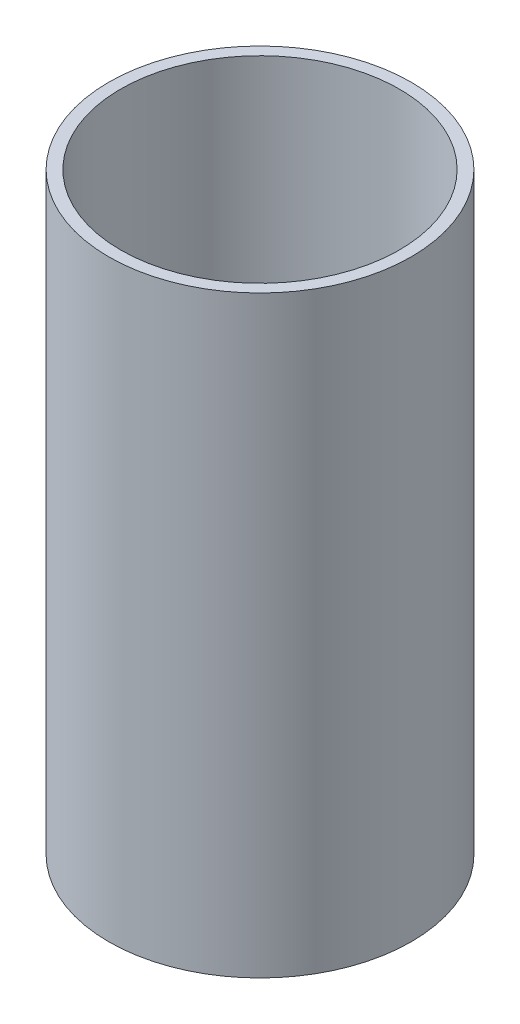
from build123d import *

# Parameters (mm, degrees)
SKETCH1_R           = 25.5
SKETCH1_R_2         = 23.5
BOSS_EXTRUDE1_DEPTH = 100


with BuildPart() as part:
    # Sketch1 → Boss-Extrude1 (new body)
    with BuildSketch(Plane(origin=(0, 0, 0), x_dir=(1, 0, 0), z_dir=(0, 1, 0))):
        Circle(SKETCH1_R)
        Circle(SKETCH1_R_2, mode=Mode.SUBTRACT)
    extrude(amount=BOSS_EXTRUDE1_DEPTH)


solid = part.part
